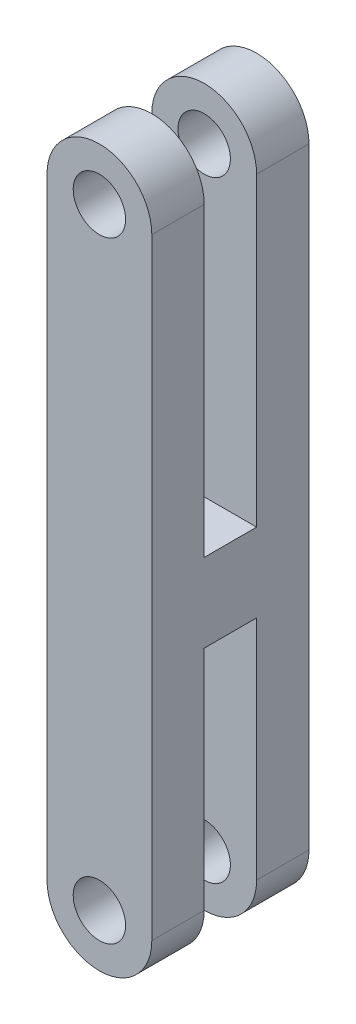
from build123d import *

# Parameters (mm, degrees)
SCHIZZO2_R                   = 1.5
ESTRUSIONE_ESTRUSIONE1_DEPTH = 9
SCHIZZO5_W                   = 3
SCHIZZO5_H                   = 20.5
SCHIZZO5_H_2                 = 16
TAGLIO_ESTRUSIONE1_DEPTH     = 15


with BuildPart() as part:
    # Schizzo2 → Estrusione-Estrusione1 (new body)
    with BuildSketch(Plane.XY):
        with BuildLine():
            Line((-3, 0), (-3, 35))
            ThreePointArc((-3, 35), (0, 38), (3, 35))
            Line((3, 35), (3, 0))
            ThreePointArc((3, 0), (0, -3), (-3, 0))
        make_face()
        with Locations((0, 35)):
            Circle(SCHIZZO2_R, mode=Mode.SUBTRACT)
        Circle(SCHIZZO2_R, mode=Mode.SUBTRACT)
    extrude(amount=ESTRUSIONE_ESTRUSIONE1_DEPTH)

    # Schizzo5 → Taglio-Estrusione1 (cut)
    with BuildSketch(Plane(origin=(3, 0, 0), x_dir=(0, 0, -1), z_dir=(1, 0, 0))):
        with Locations((-4.5, 27.75)):
            Rectangle(SCHIZZO5_W, SCHIZZO5_H)
        with Locations((-4.5, 5)):
            Rectangle(SCHIZZO5_W, SCHIZZO5_H_2)
    extrude(amount=-TAGLIO_ESTRUSIONE1_DEPTH, mode=Mode.SUBTRACT)


solid = part.part
